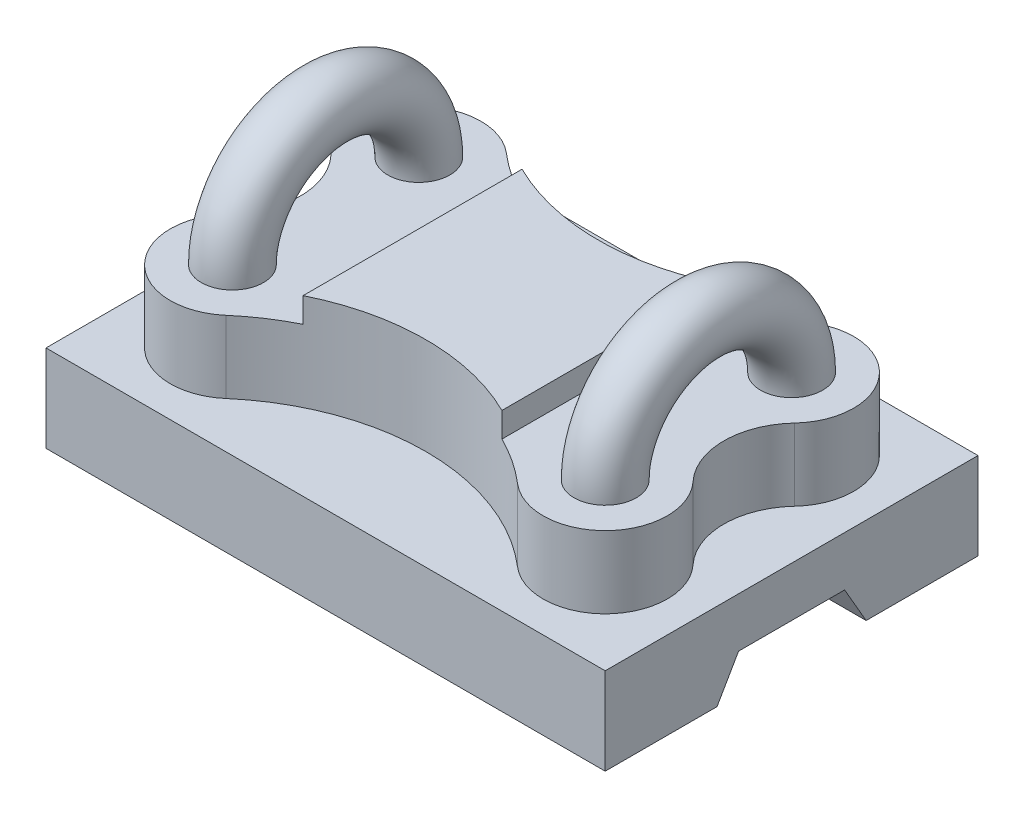
from build123d import *

# Parameters (mm, degrees)
SKETCH1_W           = 450
SKETCH1_H           = 300
BOSS_EXTRUDE1_DEPTH = 70
CUT_EXTRUDE1_DEPTH  = 451
SKETCH3_R           = 25
BOSS_EXTRUDE2_DEPTH = 58
BOSS_EXTRUDE3_DEPTH = 20
SKETCH5_R           = 25
REVOLVE1_ANGLE      = 180


with BuildPart() as part:
    # Sketch1 → Boss-Extrude1 (new body)
    with BuildSketch(Plane(origin=(0, 0, 0), x_dir=(1, 0, 0), z_dir=(0, 1, 0))):
        Rectangle(SKETCH1_W, SKETCH1_H)
    extrude(amount=BOSS_EXTRUDE1_DEPTH)

    # Sketch2 → Cut-Extrude1 (cut, through all)
    with BuildSketch(Plane(origin=(225, 0, 0), x_dir=(0, 0, -1), z_dir=(1, 0, 0))):
        Polygon((-60, 0), (-42.679491924, 30), (42.679491924, 30), (60, 0), align=None)
    extrude(amount=-CUT_EXTRUDE1_DEPTH, mode=Mode.SUBTRACT)

    # Sketch3 → Boss-Extrude2 (add)
    with BuildSketch(Plane(origin=(0, 70, 0), x_dir=(1, 0, 0), z_dir=(0, 1, 0))):
        with BuildLine():
            Line((-80, -88.110802776), (-80, 88.110802776))
            ThreePointArc((-80, 88.110802776), (-99.471105521, 99.337628307), (-117.391304348, 112.903469074))
            ThreePointArc((-117.391304348, 112.903469074), (-186.051805285, 109.644874595), (-186.576083953, 40.909090909))
            ThreePointArc((-186.576083953, 40.909090909), (-170.467384697, 0), (-186.576083953, -40.909090909))
            ThreePointArc((-186.576083953, -40.909090909), (-186.051805285, -109.644874595), (-117.391304348, -112.903469074))
            ThreePointArc((-117.391304348, -112.903469074), (-99.471105521, -99.337628307), (-80, -88.110802776))
        make_face()
        with Locations((-150, -75)):
            Circle(SKETCH3_R, mode=Mode.SUBTRACT)
        with Locations((-150, 75)):
            Circle(SKETCH3_R, mode=Mode.SUBTRACT)
        with BuildLine():
            ThreePointArc((80, 88.110802776), (0, 69.355957742), (-80, 88.110802776))
            Line((-80, 88.110802776), (-80, -88.110802776))
            ThreePointArc((-80, -88.110802776), (0, -69.355957742), (80, -88.110802776))
            Line((80, -88.110802776), (80, 88.110802776))
        make_face()
        with BuildLine():
            ThreePointArc((117.391304348, 112.903469074), (99.471105521, 99.337628307), (80, 88.110802776))
            Line((80, 88.110802776), (80, -88.110802776))
            ThreePointArc((80, -88.110802776), (99.471105521, -99.337628307), (117.391304348, -112.903469074))
            ThreePointArc((117.391304348, -112.903469074), (186.051805285, -109.644874595), (186.576083953, -40.909090909))
            ThreePointArc((186.576083953, -40.909090909), (170.467384697, 0), (186.576083953, 40.909090909))
            ThreePointArc((186.576083953, 40.909090909), (186.051805285, 109.644874595), (117.391304348, 112.903469074))
        make_face()
        with Locations((150, -75)):
            Circle(SKETCH3_R, mode=Mode.SUBTRACT)
        with Locations((150, 75)):
            Circle(SKETCH3_R, mode=Mode.SUBTRACT)
        with Locations((-150, 75)):
            Circle(SKETCH3_R)
        with Locations((-150, -75)):
            Circle(SKETCH3_R)
        with Locations((150, -75)):
            Circle(SKETCH3_R)
        with Locations((150, 75)):
            Circle(SKETCH3_R)
    extrude(amount=BOSS_EXTRUDE2_DEPTH)

    # Sketch4 → Boss-Extrude3 (add)
    with BuildSketch(Plane(origin=(0, 128, 0), x_dir=(1, 0, 0), z_dir=(0, 1, 0))):
        with BuildLine():
            Line((-80, 88.110802776), (-80, -88.110802776))
            ThreePointArc((-80, -88.110802776), (0, -69.355957742), (80, -88.110802776))
            Line((80, -88.110802776), (80, 88.110802776))
            ThreePointArc((80, 88.110802776), (0, 69.355957742), (-80, 88.110802776))
        make_face()
    extrude(amount=BOSS_EXTRUDE3_DEPTH)

    # Sketch5 → Revolve1 (revolve)
    with BuildSketch(Plane(origin=(0, 128, 0), x_dir=(1, 0, 0), z_dir=(0, 1, 0))):
        with Locations((-150, 75)):
            Circle(SKETCH5_R)
        with Locations((150, 75)):
            Circle(SKETCH5_R)
    revolve(axis=Axis((-226.209198956, 128, 0), (1, 0, 0)), revolution_arc=REVOLVE1_ANGLE)


solid = part.part
